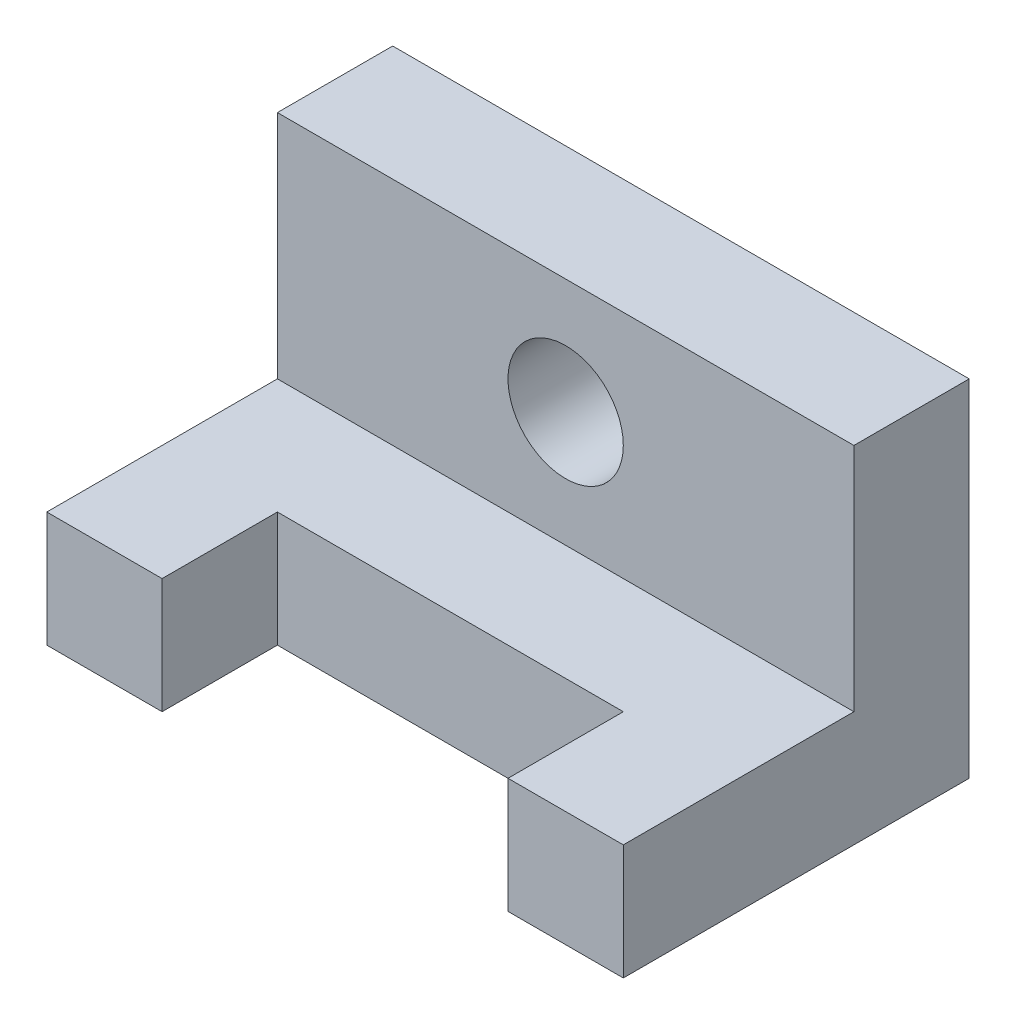
from build123d import *

# Parameters (mm, degrees)
BOSS_EXTRUDE1_DEPTH = 50
CUT_EXTRUDE1_REACH  = 22
SKETCH2_W           = 60
SKETCH2_H           = 20
CUT_EXTRUDE2_REACH  = 22
SKETCH3_R           = 10


with BuildPart() as part:
    # Sketch1 → Boss-Extrude1 (new body, symmetric)
    with BuildSketch(Plane(origin=(0, 0, 0), x_dir=(0, 0, -1), z_dir=(1, 0, 0))):
        Polygon((0, 60), (0, 0), (-60, 0), (-60, 20), (-20, 20), (-20, 60), align=None)
    extrude(amount=BOSS_EXTRUDE1_DEPTH, both=True)

    # Sketch2 → Cut-Extrude1 (cut, up to next)
    with BuildSketch(Plane(origin=(0, 20, 0), x_dir=(1, 0, 0), z_dir=(0, 1, 0)), mode=Mode.PRIVATE) as cut_extrude1_sk1:
        with Locations((0, -50)):
            Rectangle(SKETCH2_W, SKETCH2_H)
    cut_extrude1_tool1 = extrude(cut_extrude1_sk1.sketch, amount=-CUT_EXTRUDE1_REACH, mode=Mode.PRIVATE) & part.part
    add(cut_extrude1_tool1.solids().sort_by_distance((0, 20, 50))[0], mode=Mode.SUBTRACT)

    # Sketch3 → Cut-Extrude2 (cut, up to next)
    with BuildSketch(Plane.XY.offset(20), mode=Mode.PRIVATE) as cut_extrude2_sk1:
        with Locations((0, 40)):
            Circle(SKETCH3_R)
    cut_extrude2_tool1 = extrude(cut_extrude2_sk1.sketch, amount=-CUT_EXTRUDE2_REACH, mode=Mode.PRIVATE) & part.part
    add(cut_extrude2_tool1.solids().sort_by_distance((0, 40, 20))[0], mode=Mode.SUBTRACT)


solid = part.part
